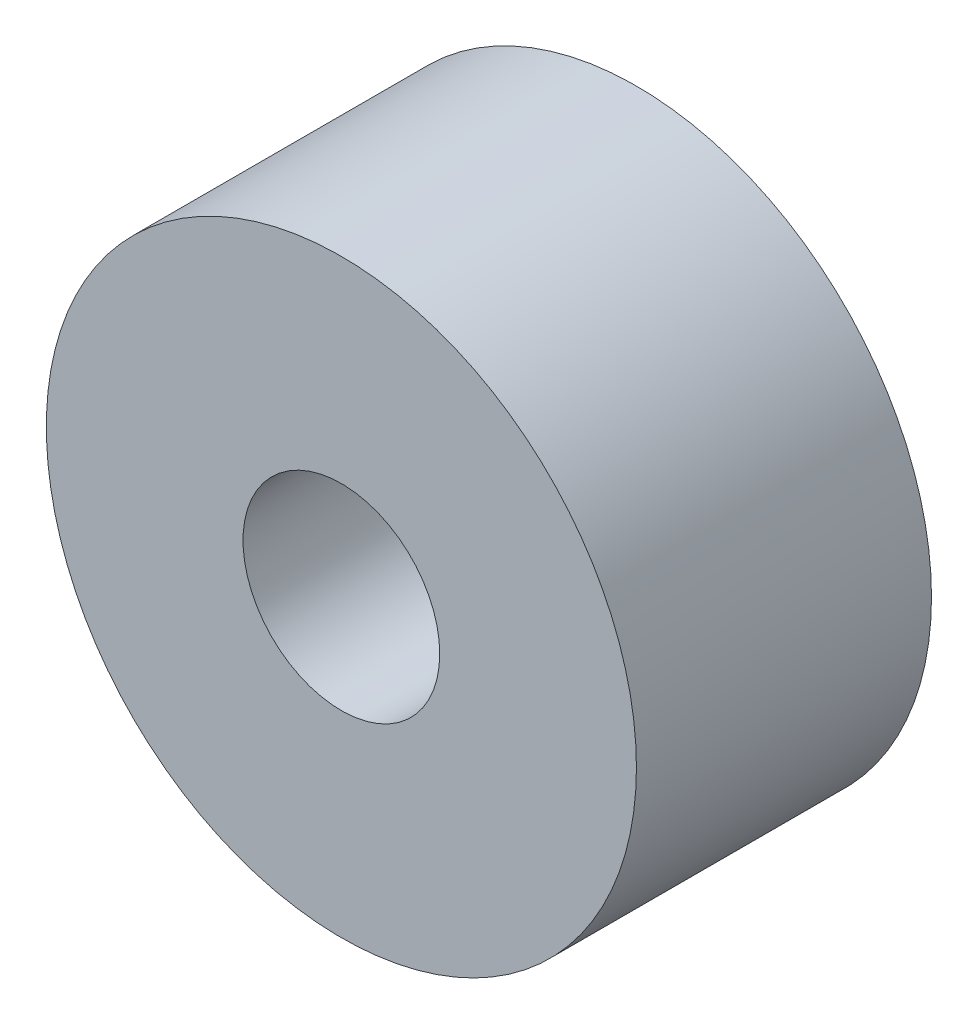
from build123d import *

# Parameters (mm, degrees)
ESQUISSE1_W = 3
ESQUISSE1_H = 2


with BuildPart() as part:
    # Esquisse1 → Révolution1 (revolve)
    with BuildSketch(Plane(origin=(0, 0, 0), x_dir=(0, 0, -1), z_dir=(1, 0, 0))):
        with Locations((0, 2)):
            Rectangle(ESQUISSE1_W, ESQUISSE1_H)
    revolve(axis=Axis((0, 0, 0), (0, 0, -1)))


solid = part.part
